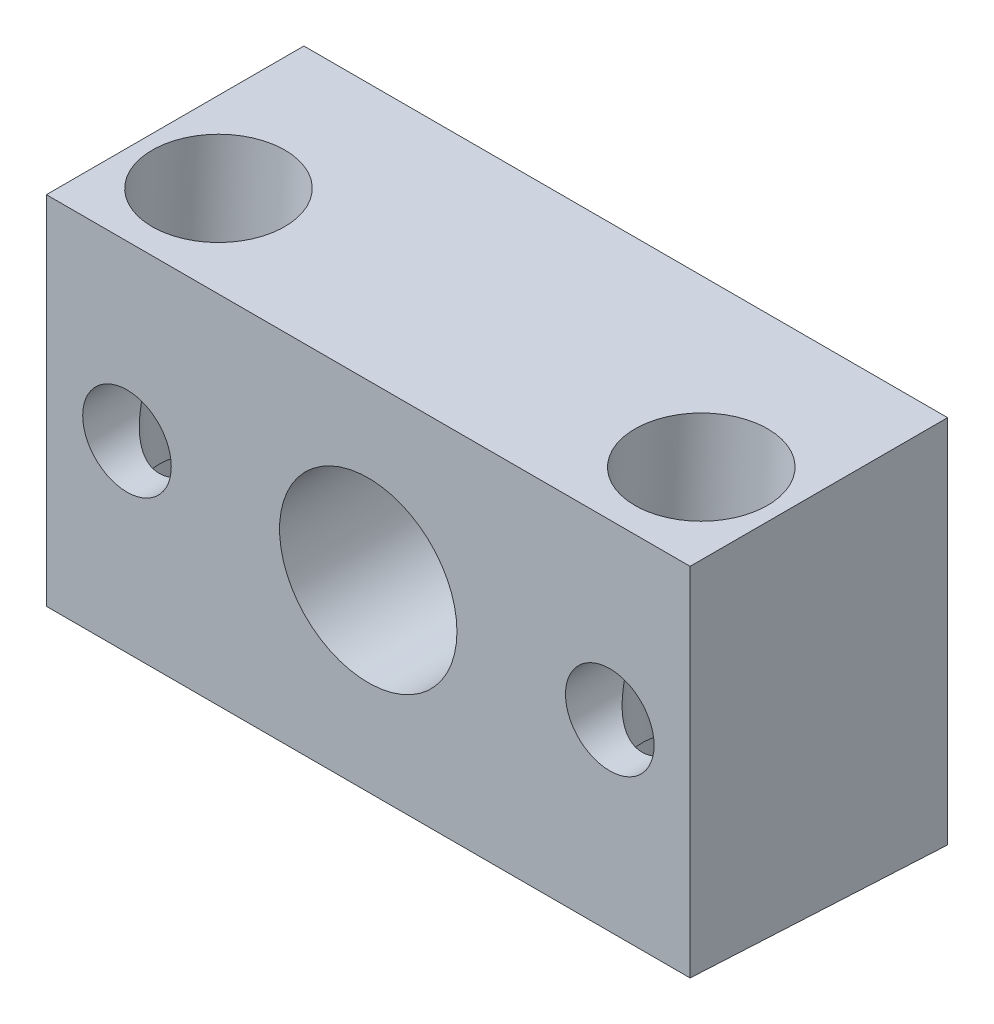
from build123d import *

# Parameters (mm, degrees)
SKETCH1_W          = 63.5
SKETCH1_H          = 36.4998
SKETCH1_R          = 8.7503
SKETCH1_R_2        = 4.3688
EXTRUDE1_DEPTH     = 25.4
CUT_EXTRUDE1_DEPTH = 64.5
LPATTERN1_COUNT    = 2
LPATTERN1_PITCH    = 47.625


with BuildPart() as part:
    # Sketch1 → Extrude1 (new body)
    with BuildSketch(Plane.XY):
        with Locations((0, -1.1811)):
            Rectangle(SKETCH1_W, SKETCH1_H)
        Circle(SKETCH1_R, mode=Mode.SUBTRACT)
        with Locations((-23.7998, 0)):
            Circle(SKETCH1_R_2, mode=Mode.SUBTRACT)
        with Locations((23.8252, 0)):
            Circle(SKETCH1_R_2, mode=Mode.SUBTRACT)
    extrude(amount=EXTRUDE1_DEPTH)

    # Sketch2 → Cut-Extrude1 (cut, through all)
    with BuildSketch(Plane(origin=(31.75, 0, 0), x_dir=(0, 0, -1), z_dir=(1, 0, 0))):
        Polygon((0, -19.431), (-25.4, -18.099842406), (-25.4, -19.431), align=None)
    extrude(amount=-CUT_EXTRUDE1_DEPTH, mode=Mode.SUBTRACT)

    # Sketch3 → Cut-Revolve1 (revolve, cut)
    with BuildSketch(Plane(origin=(-23.7998, 0, 0), x_dir=(0, 0, -1), z_dir=(1, 0, 0)), mode=Mode.PRIVATE) as cut_revolve1_sk:
        Polygon((-10.9093, -18.859267813), (-10.9093, -8.3312), (-12.6873, -8.3312), (-12.6873, 17.0688), (-17.4498, 17.0688), (-17.4498, -18.859267813), align=None)
    cut_revolve1 = revolve(cut_revolve1_sk.sketch.rotate(Axis((-23.7998, 16.931830478, 17.4498), (0, -1, 0)), 180), axis=Axis((-23.7998, 16.931830478, 17.4498), (0, -1, 0)), mode=Mode.SUBTRACT)  # turned: the seam where the file's is

    # Sketch4 → Cut-Revolve2 (revolve, cut)
    with BuildSketch(Plane(origin=(-23.7998, 0, 0), x_dir=(0, 0, -1), z_dir=(1, 0, 0)), mode=Mode.PRIVATE) as cut_revolve2_sk:
        Polygon((-9.825313315, 17.0688), (-10.376701981, 6.547677495), (-16.908238453, 6.889980817), (-16.356849787, 17.411103322), align=None)
    cut_revolve2 = revolve(cut_revolve2_sk.sketch.rotate(Axis((-23.7998, 21.413272844, 16.14710497), (0, -0.998629535, 0.052335956)), 180), axis=Axis((-23.7998, 21.413272844, 16.14710497), (0, -0.998629535, 0.052335956)), mode=Mode.SUBTRACT)  # turned: the seam where the file's is

    # LPattern1: Cut-Revolve1, Cut-Revolve2 ×2
    with Locations(*[(i * LPATTERN1_PITCH, 0, 0) for i in range(1, LPATTERN1_COUNT)]):
        add(cut_revolve1, mode=Mode.SUBTRACT)
        add(cut_revolve2, mode=Mode.SUBTRACT)


solid = part.part
